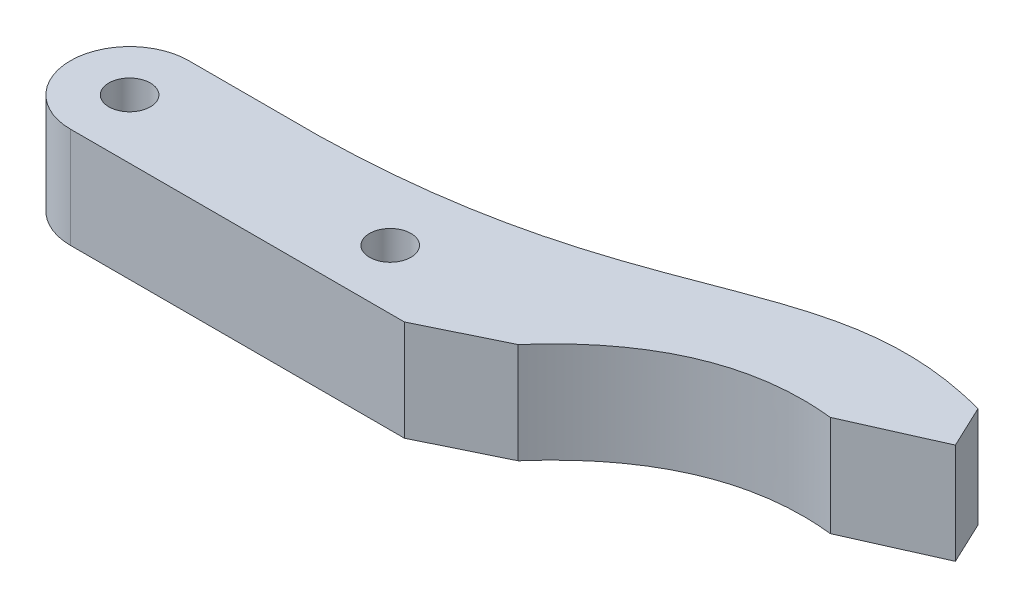
from build123d import *

# Parameters (mm, degrees)
SKETCH1_R           = 5000
SKETCH1_R_2         = 1750
BOSS_EXTRUDE1_DEPTH = 8500
BOSS_EXTRUDE2_DEPTH = 8500


with BuildPart() as part:
    # Sketch1 → Boss-Extrude1 (new body)
    with BuildSketch(Plane(origin=(0, 0, 0), x_dir=(1, 0, 0), z_dir=(0, 1, 0))):
        Circle(SKETCH1_R)
        Circle(SKETCH1_R_2, mode=Mode.SUBTRACT)
        with BuildLine():
            Line((22000, 5000), (-4.2951e-05, 5000))
            ThreePointArc((-4.2951e-05, 5000), (3535.533890747, 3535.533921118), (5000, 0))
            ThreePointArc((5000, 0), (3535.533905933, -3535.533905933), (0, -5000))
            Line((0, -5000), (22000, -5000))
            ThreePointArc((22000, -5000), (17000, 0), (22000, 5000))
        make_face()
        with Locations((22000, 0)):
            Circle(SKETCH1_R)
        with Locations((22000, 0)):
            Circle(SKETCH1_R_2, mode=Mode.SUBTRACT)
    extrude(amount=BOSS_EXTRUDE1_DEPTH)

    # Sketch2 → Boss-Extrude2 (add)
    with BuildSketch(Plane(origin=(0, 8500, 0), x_dir=(1, 0, 0), z_dir=(0, 1, 0))):
        with BuildLine():
            Line((22000, -5000), (28197.409679947, -5000))
            Line((28197.409679947, -5000), (34649.356853801, -1853.175103606))
            add(Edge.make_bspline(
                [(34649.356853801, -1853.175103606), (42552.502002918, 7200.871322652), (53148.794169675, 6000)],
                knots=[0, 0, 0, 1, 1, 1], degree=2))
            Line((53148.794169675, 6000), (60457.635009592, 9252.821171961))
            Line((60457.635009592, 9252.821171961), (58750, 12870))
            add(Edge.make_bspline(
                [(11000, 5000), (38094.669145956, 5526.947568374), (42172.496557994, 17338.223006618), (58750, 12870)],
                knots=[0, 0, 0, 0, 1, 1, 1, 1], degree=3))
            Line((11000, 5000), (22000, 5000))
            ThreePointArc((22000, 5000), (27000, 0), (22000, -5000))
        make_face()
    extrude(amount=-BOSS_EXTRUDE2_DEPTH)


solid = part.part
